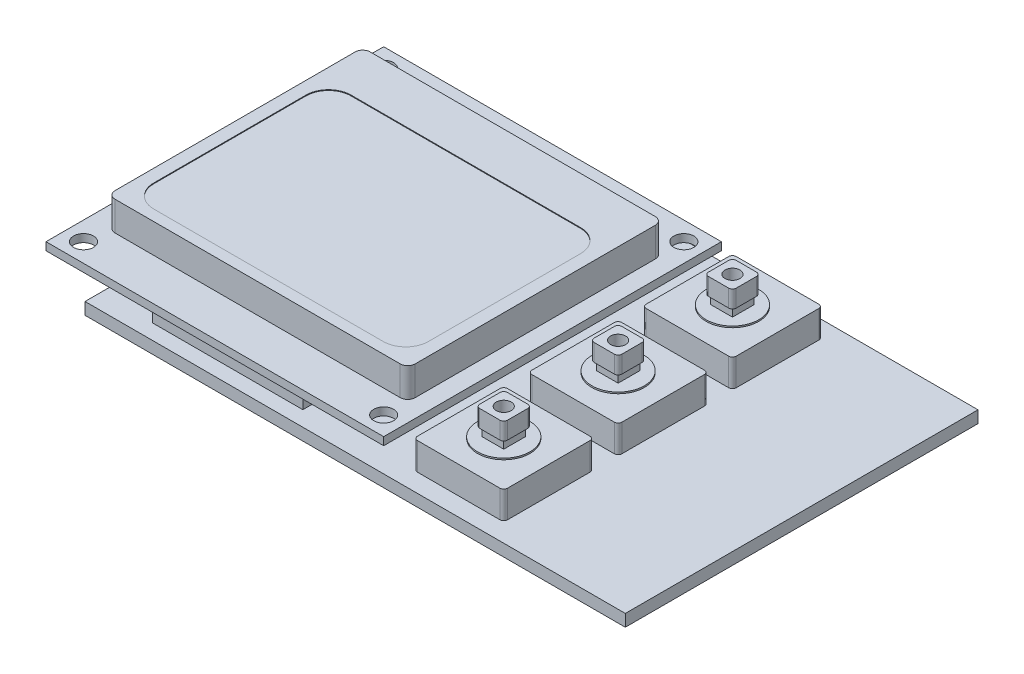
from build123d import *

# Parameters (mm, degrees)
SKETCH1_W              = 72
SKETCH1_H              = 47
BOSS_EXTRUDE1_DEPTH    = 1.6
SKETCH2_W              = 20
SKETCH2_H              = 3
BOSS_EXTRUDE2_DEPTH    = 2.6
SKETCH3_W              = 45
SKETCH3_H              = 45
SKETCH3_R              = 1.325
BOSS_EXTRUDE3_DEPTH    = 1.05
SKETCH4_W              = 40
SKETCH4_H              = 34
BOSS_EXTRUDE4_DEPTH    = 3.9
CUT_EXTRUDE1_DEPTH     = 0.1
FILLET1_R              = 1
SKETCH6_W              = 12
SKETCH6_H              = 12
BOSS_EXTRUDE5_DEPTH    = 3.65
SKETCH7_R              = 3.5
BOSS_EXTRUDE6_DEPTH    = 0.2
SKETCH8_W              = 2.9
SKETCH8_H              = 2.9
BOSS_EXTRUDE7_DEPTH    = 1.2
SKETCH9_W              = 3.7
SKETCH9_H              = 3.7
BOSS_EXTRUDE8_DEPTH    = 2.3
FILLET2_R              = 0.5
SKETCH10_R             = 1
CUT_EXTRUDE2_DEPTH     = 3
LPATTERN1_COUNT        = 3
LPATTERN1_PITCH        = 15.24
FILLET2_OF_LPATTERN1_R = 0.5


with BuildPart() as part:
    # Sketch1 → Boss-Extrude1 (new body)
    with BuildSketch(Plane(origin=(0, 0, 0), x_dir=(1, 0, 0), z_dir=(0, 1, 0))):
        Rectangle(SKETCH1_W, SKETCH1_H)
    extrude(amount=BOSS_EXTRUDE1_DEPTH)

    # Sketch2 → Boss-Extrude2 (add)
    with BuildSketch(Plane(origin=(0, 1.6, 0), x_dir=(1, 0, 0), z_dir=(0, 1, 0))):
        with Locations((-19, -19.975114796)):
            Rectangle(SKETCH2_W, SKETCH2_H)
        with Locations((-19, 19.975114796)):
            Rectangle(SKETCH2_W, SKETCH2_H)
    extrude(amount=BOSS_EXTRUDE2_DEPTH)

    # Sketch3 → Boss-Extrude3 (add)
    with BuildSketch(Plane(origin=(0, 4.2, 0), x_dir=(1, 0, 0), z_dir=(0, 1, 0))):
        with Locations((-19.35, -0.35)):
            Rectangle(SKETCH3_W, SKETCH3_H)
        with Locations((-39.35, 19.65)):
            Circle(SKETCH3_R, mode=Mode.SUBTRACT)
        with Locations((0.65, 19.65)):
            Circle(SKETCH3_R, mode=Mode.SUBTRACT)
        with Locations((0.65, -20.35)):
            Circle(SKETCH3_R, mode=Mode.SUBTRACT)
        with Locations((-39.35, -20.35)):
            Circle(SKETCH3_R, mode=Mode.SUBTRACT)
    extrude(amount=BOSS_EXTRUDE3_DEPTH)

    # Sketch4 → Boss-Extrude4 (add)
    with BuildSketch(Plane(origin=(0, 5.25, 0), x_dir=(1, 0, 0), z_dir=(0, 1, 0))):
        with Locations((-19.25, -0.25)):
            Rectangle(SKETCH4_W, SKETCH4_H)
    extrude(amount=BOSS_EXTRUDE4_DEPTH)

    # Sketch5 → Cut-Extrude1 (cut)
    with BuildSketch(Plane(origin=(0, 9.15, 0), x_dir=(1, 0, 0), z_dir=(0, 1, 0))):
        with BuildLine():
            Line((-34.55, -15.8), (-3.95, -15.8))
            ThreePointArc((-3.95, -15.8), (-1.828679656, -14.921320344), (-0.95, -12.8))
            Line((-0.95, -12.8), (-0.95, 7.5))
            ThreePointArc((-0.95, 7.5), (-1.828679656, 9.621320344), (-3.95, 10.5))
            Line((-3.95, 10.5), (-34.55, 10.5))
            ThreePointArc((-34.55, 10.5), (-36.671320344, 9.621320344), (-37.55, 7.5))
            Line((-37.55, 7.5), (-37.55, -12.8))
            ThreePointArc((-37.55, -12.8), (-36.671320344, -14.921320344), (-34.55, -15.8))
        make_face()
    extrude(amount=-CUT_EXTRUDE1_DEPTH, mode=Mode.SUBTRACT)

    # Fillet1
    fillet1_edges = [part.edges().sort_by_distance(p)[0] for p in [
        (-39.25, 7.2, -16.75),
        (-39.25, 7.2, 17.25),
        (0.75, 7.2, 17.25),
        (0.75, 7.2, -16.75),
    ]]
    fillet(fillet1_edges, radius=FILLET1_R)

    # Sketch6 → Boss-Extrude5 (add)
    with BuildSketch(Plane(origin=(0, 1.6, 0), x_dir=(1, 0, 0), z_dir=(0, 1, 0))):
        with Locations((11.35, -15.05)):
            Rectangle(SKETCH6_W, SKETCH6_H)
    boss_extrude5 = extrude(amount=BOSS_EXTRUDE5_DEPTH)

    # Sketch7 → Boss-Extrude6 (add)
    with BuildSketch(Plane(origin=(0, 5.25, 0), x_dir=(1, 0, 0), z_dir=(0, 1, 0))):
        with Locations((11.35, -15.05)):
            Circle(SKETCH7_R)
    boss_extrude6 = extrude(amount=BOSS_EXTRUDE6_DEPTH)

    # Sketch8 → Boss-Extrude7 (add)
    with BuildSketch(Plane(origin=(0, 5.45, 0), x_dir=(1, 0, 0), z_dir=(0, 1, 0))):
        with Locations((11.35, -15.05)):
            Rectangle(SKETCH8_W, SKETCH8_H)
    boss_extrude7 = extrude(amount=BOSS_EXTRUDE7_DEPTH)

    # Sketch9 → Boss-Extrude8 (add)
    with BuildSketch(Plane(origin=(0, 6.65, 0), x_dir=(1, 0, 0), z_dir=(0, 1, 0))):
        with Locations((11.35, -15.05)):
            Rectangle(SKETCH9_W, SKETCH9_H)
    boss_extrude8 = extrude(amount=BOSS_EXTRUDE8_DEPTH)

    # Fillet2
    fillet2_edges = [part.edges().sort_by_distance(p)[0] for p in [
        (5.35, 3.425, 9.05),
        (5.35, 3.425, 21.05),
        (17.35, 3.425, 21.05),
        (17.35, 3.425, 9.05),
        (9.5, 7.8, 13.2),
        (9.5, 7.8, 16.9),
        (13.2, 7.8, 16.9),
        (13.2, 7.8, 13.2),
    ]]
    fillet(fillet2_edges, radius=FILLET2_R)

    # Sketch10 → Cut-Extrude2 (cut)
    with BuildSketch(Plane(origin=(0, 8.95, 0), x_dir=(1, 0, 0), z_dir=(0, 1, 0))):
        with Locations((11.35, -15.05)):
            Circle(SKETCH10_R)
    cut_extrude2 = extrude(amount=-CUT_EXTRUDE2_DEPTH, mode=Mode.SUBTRACT)

    # LPattern1: Boss-Extrude5, Boss-Extrude6, Boss-Extrude7, Boss-Extrude8, Cut-Extrude2 ×3
    with Locations(*[(0, 0, -i * LPATTERN1_PITCH) for i in range(1, LPATTERN1_COUNT)]):
        add(boss_extrude5)
        add(boss_extrude6)
        add(boss_extrude7)
        add(boss_extrude8)
        add(cut_extrude2, mode=Mode.SUBTRACT)

    # Fillet2 of LPattern1
    fillet2_of_lpattern1_edges = [part.edges().sort_by_distance(p)[0] for p in [
        (5.35, 3.425, -6.19),
        (5.35, 3.425, 5.81),
        (17.35, 3.425, 5.81),
        (17.35, 3.425, -6.19),
        (9.5, 7.8, -2.04),
        (9.5, 7.8, 1.66),
        (13.2, 7.8, 1.66),
        (13.2, 7.8, -2.04),
        (5.35, 3.425, -21.43),
        (5.35, 3.425, -9.43),
        (17.35, 3.425, -9.43),
        (17.35, 3.425, -21.43),
        (9.5, 7.8, -17.28),
        (9.5, 7.8, -13.58),
        (13.2, 7.8, -13.58),
        (13.2, 7.8, -17.28),
    ]]
    fillet(fillet2_of_lpattern1_edges, radius=FILLET2_OF_LPATTERN1_R)


solid = part.part
